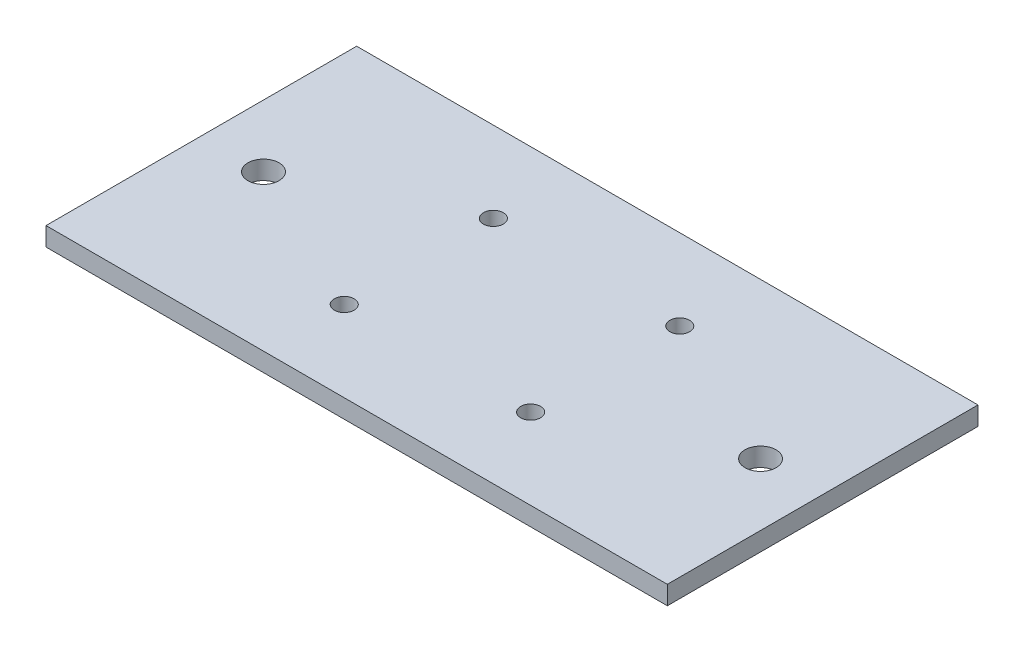
from build123d import *

# Parameters (mm, degrees)
SKETCH2_W           = 100
SKETCH2_H           = 50
BOSS_EXTRUDE2_DEPTH = 3
SKETCH5_R           = 2.5
SKETCH5_R_2         = 1.6
CUT_EXTRUDE1_DEPTH  = 3


with BuildPart() as part:
    # Sketch2 → Boss-Extrude2 (new body)
    with BuildSketch(Plane(origin=(0, 0, 0), x_dir=(1, 0, 0), z_dir=(0, 1, 0))):
        Rectangle(SKETCH2_W, SKETCH2_H)
    extrude(amount=BOSS_EXTRUDE2_DEPTH)

    # Sketch5 → Cut-Extrude1 (cut)
    with BuildSketch(Plane(origin=(0, 3, 0), x_dir=(1, 0, 0), z_dir=(0, 1, 0))):
        with Locations((-40, 0)):
            Circle(SKETCH5_R)
        with Locations((40, 0)):
            Circle(SKETCH5_R)
        with Locations((-15, 12)):
            Circle(SKETCH5_R_2)
        with Locations((-15, -12)):
            Circle(SKETCH5_R_2)
        with Locations((15, 12)):
            Circle(SKETCH5_R_2)
        with Locations((15, -12)):
            Circle(SKETCH5_R_2)
    extrude(amount=-CUT_EXTRUDE1_DEPTH, mode=Mode.SUBTRACT)


solid = part.part
